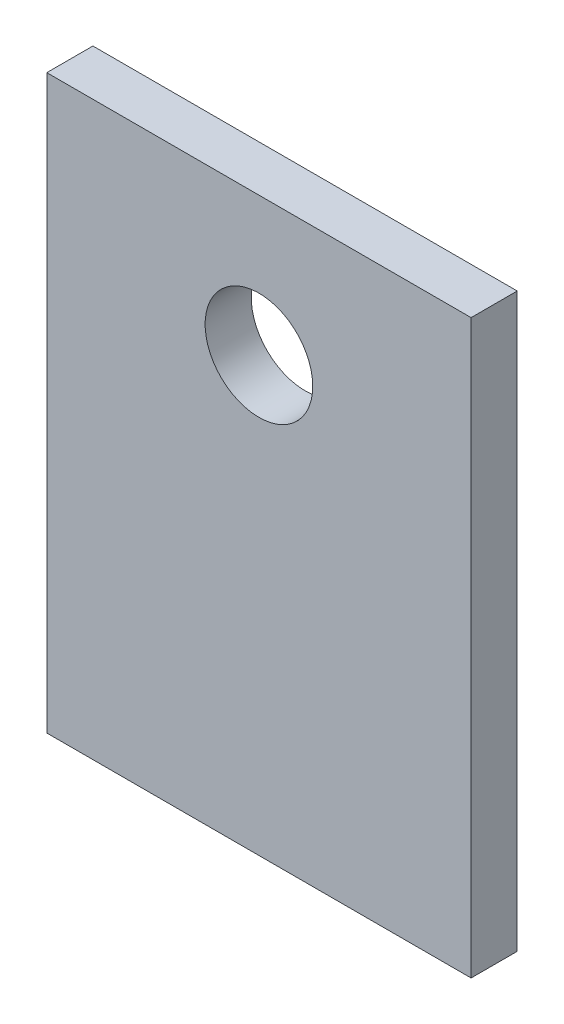
from build123d import *

# Parameters (mm, degrees)
SKETCH_1_W      = 13.8
SKETCH_1_H      = 18.6
SKETCH_1_R      = 1.75
EXTRUDE_2_DEPTH = 1.5


with BuildPart() as part:
    # Эскиз1 → Бобышка-Вытянуть2 (new body)
    with BuildSketch(Plane(origin=(0, 0, 0), x_dir=(-1, 0, 0), z_dir=(0, 0, 1))):
        Rectangle(SKETCH_1_W, SKETCH_1_H)
        with Locations((0, -4.79)):
            Circle(SKETCH_1_R, mode=Mode.SUBTRACT)
    extrude(amount=EXTRUDE_2_DEPTH)


solid = part.part
